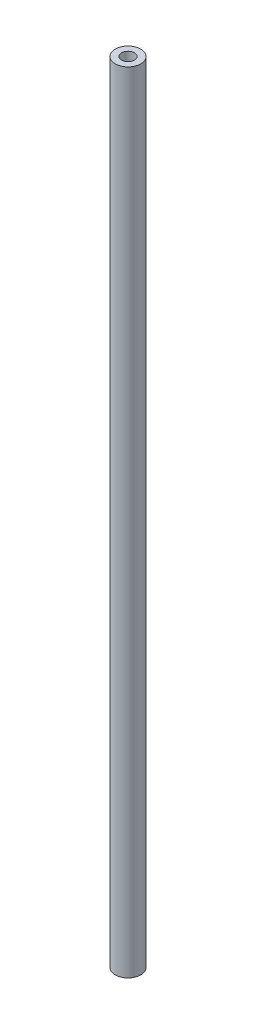
from build123d import *

# Parameters (mm, degrees)
SKETCH1_R           = 6.35
SKETCH1_R_2         = 3.175
BOSS_EXTRUDE1_DEPTH = 391.414


with BuildPart() as part:
    # Sketch1 → Boss-Extrude1 (new body)
    with BuildSketch(Plane(origin=(0, 0, 0), x_dir=(1, 0, 0), z_dir=(0, 1, 0))):
        Circle(SKETCH1_R)
        Circle(SKETCH1_R_2, mode=Mode.SUBTRACT)
    extrude(amount=BOSS_EXTRUDE1_DEPTH)


solid = part.part
